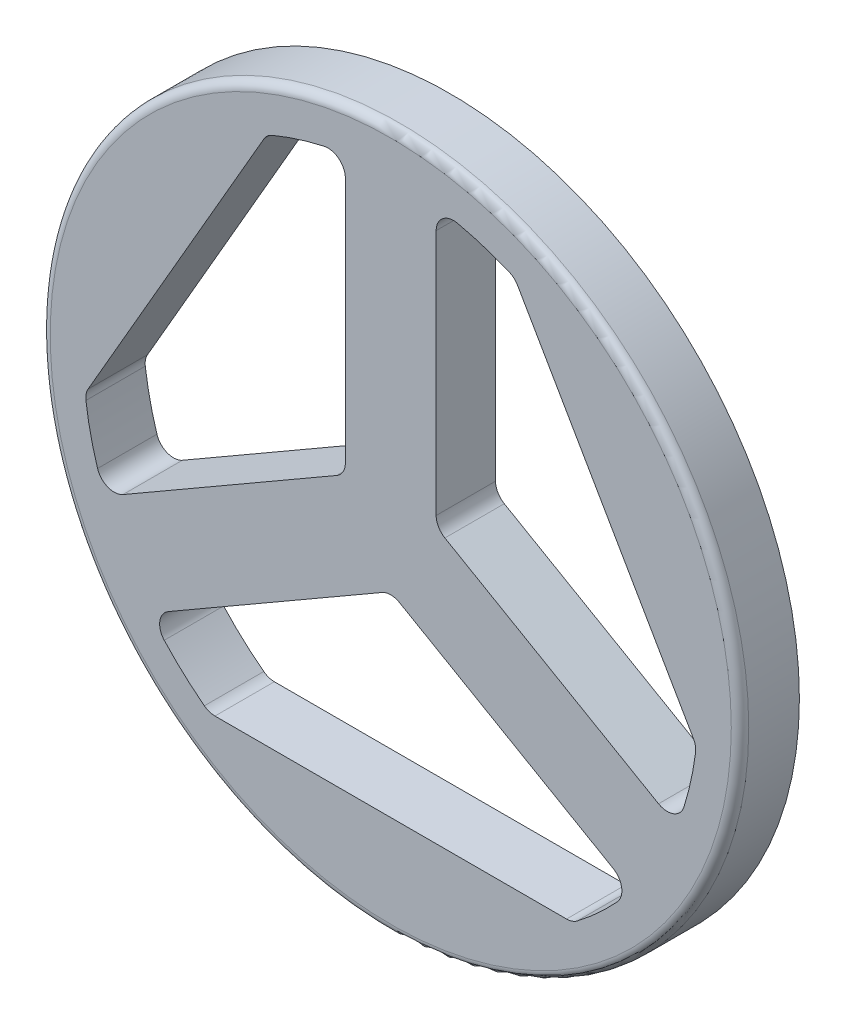
from build123d import *

# Parameters (mm, degrees)
ESBO_O2_R             = 200
EXTRUS_O2_DEPTH       = 34
EXTRUS_O3_DEPTH       = 35
PADR_OCIRCULAR1_COUNT = 3
CASCA1_T              = -3
FILETE1_R             = 10
FILETE2_R             = 10
FILETE3_R             = 10
FILETE4_R             = 10
FILETE5_R             = 10
FILETE6_R             = 10
FILETE7_R             = 10
FILETE8_R             = 10
FILETE9_R             = 10
FILETE10_R            = 10
FILETE11_R            = 10
FILETE12_R            = 10
FILETE13_R            = 10
FILETE14_R            = 10
FILETE15_R            = 10
FILETE16_R            = 10
FILETE17_R            = 10
FILETE18_R            = 10
FILETE19_R            = 5


with BuildPart() as part:
    # Esboço2 → Extrusão2 (new body)
    with BuildSketch(Plane.XY):
        Circle(ESBO_O2_R)
    extrude(amount=EXTRUS_O2_DEPTH)

    # Esboço4 → Extrusão3 (cut, through all)
    with BuildSketch(Plane.XY.offset(34)):
        with BuildLine():
            Line((-103.980767452, -142), (103.980767452, -142))
            ThreePointArc((103.980767452, -142), (121.948545192, -126.903712812), (137.748134317, -109.551136426))
            Line((137.748134317, -109.551136426), (0, -30.022213998))
            Line((0, -30.022213998), (-137.748134317, -109.551136426))
            ThreePointArc((-137.748134317, -109.551136426), (-121.948545192, -126.903712812), (-103.980767452, -142))
        make_face()
    extrus_o3 = extrude(amount=-EXTRUS_O3_DEPTH, mode=Mode.SUBTRACT)

    # PadrãoCircular1: Extrusão3 ×3 about axis
    padr_ocircular1_axis = Axis((0, 0, 0), (0, 0, 1))
    for i in range(1, PADR_OCIRCULAR1_COUNT):
        add(extrus_o3.rotate(padr_ocircular1_axis, i * 360 / PADR_OCIRCULAR1_COUNT), mode=Mode.SUBTRACT)

    # Casca1
    casca1_openings = [part.faces().sort_by_distance(p)[0] for p in [
        (92.730670551, 53.538077605, 0),
    ]]
    offset(amount=CASCA1_T, openings=casca1_openings, kind=Kind.INTERSECTION)

    # Filete1
    filete1_edges = [part.edges().sort_by_distance(p)[0] for p in [
        (-137.748134317, -109.551136426, 17),
    ]]
    fillet(filete1_edges, radius=FILETE1_R)

    # Filete2
    filete2_edges = [part.edges().sort_by_distance(p)[0] for p in [
        (137.748134317, -109.551136426, 17),
    ]]
    fillet(filete2_edges, radius=FILETE2_R)

    # Filete3
    filete3_edges = [part.edges().sort_by_distance(p)[0] for p in [
        (-26, 174.068951855, 17),
    ]]
    fillet(filete3_edges, radius=FILETE3_R)

    # Filete4
    filete4_edges = [part.edges().sort_by_distance(p)[0] for p in [
        (-163.748134317, -64.517815429, 17),
    ]]
    fillet(filete4_edges, radius=FILETE4_R)

    # Filete5
    filete5_edges = [part.edges().sort_by_distance(p)[0] for p in [
        (26, 174.068951855, 17),
    ]]
    fillet(filete5_edges, radius=FILETE5_R)

    # Filete6
    filete6_edges = [part.edges().sort_by_distance(p)[0] for p in [
        (163.748134317, -64.517815429, 17),
    ]]
    fillet(filete6_edges, radius=FILETE6_R)

    # Filete7
    filete7_edges = [part.edges().sort_by_distance(p)[0] for p in [
        (0, -30.022213998, 17),
    ]]
    fillet(filete7_edges, radius=FILETE7_R)

    # Filete8
    filete8_edges = [part.edges().sort_by_distance(p)[0] for p in [
        (-26, 15.011106999, 17),
    ]]
    fillet(filete8_edges, radius=FILETE8_R)

    # Filete9
    filete9_edges = [part.edges().sort_by_distance(p)[0] for p in [
        (26, 15.011106999, 17),
    ]]
    fillet(filete9_edges, radius=FILETE9_R)

    # Filete10
    filete10_edges = [part.edges().sort_by_distance(p)[0] for p in [
        (-70.985223611, 161.049986119, 17),
    ]]
    fillet(filete10_edges, radius=FILETE10_R)

    # Filete11
    filete11_edges = [part.edges().sort_by_distance(p)[0] for p in [
        (-174.965991064, -19.049986119, 17),
    ]]
    fillet(filete11_edges, radius=FILETE11_R)

    # Filete12
    filete12_edges = [part.edges().sort_by_distance(p)[0] for p in [
        (-103.980767452, -142, 17),
    ]]
    fillet(filete12_edges, radius=FILETE12_R)

    # Filete13
    filete13_edges = [part.edges().sort_by_distance(p)[0] for p in [
        (103.980767452, -142, 17),
    ]]
    fillet(filete13_edges, radius=FILETE13_R)

    # Filete14
    filete14_edges = [part.edges().sort_by_distance(p)[0] for p in [
        (174.965991064, -19.049986119, 17),
    ]]
    fillet(filete14_edges, radius=FILETE14_R)

    # Filete15
    filete15_edges = [part.edges().sort_by_distance(p)[0] for p in [
        (70.985223611, 161.049986119, 17),
    ]]
    fillet(filete15_edges, radius=FILETE15_R)

    # Filete16
    filete16_edges = [part.edges().sort_by_distance(p)[0] for p in [
        (-142.233535704, -108.676682509, 15.5),
        (0, -26.558112383, 15.5),
        (-104.957134107, -145, 15.5),
        (-165.233535704, -68.839513935, 15.5),
        (-178.052250602, -18.395544445, 15.5),
        (-73.095116495, 163.395544445, 15.5),
        (165.233535704, -68.839513935, 15.5),
        (23, 13.279056191, 15.5),
        (23, 177.516196444, 15.5),
    ]]
    fillet(filete16_edges, radius=FILETE16_R)

    # Filete17
    filete17_edges = [part.edges().sort_by_distance(p)[0] for p in [
        (142.233535704, -108.676682509, 15.5),
        (104.957134107, -145, 15.5),
        (-23, 177.516196444, 15.5),
        (-23, 13.279056191, 15.5),
    ]]
    fillet(filete17_edges, radius=FILETE17_R)

    # Filete18
    filete18_edges = [part.edges().sort_by_distance(p)[0] for p in [
        (73.095116495, 163.395544445, 15.5),
        (178.052250602, -18.395544445, 15.5),
    ]]
    fillet(filete18_edges, radius=FILETE18_R)

    # Filete19
    filete19_edges = [part.edges().sort_by_distance(p)[0] for p in [
        (-200, 0, 34),
    ]]
    fillet(filete19_edges, radius=FILETE19_R)


solid = part.part
